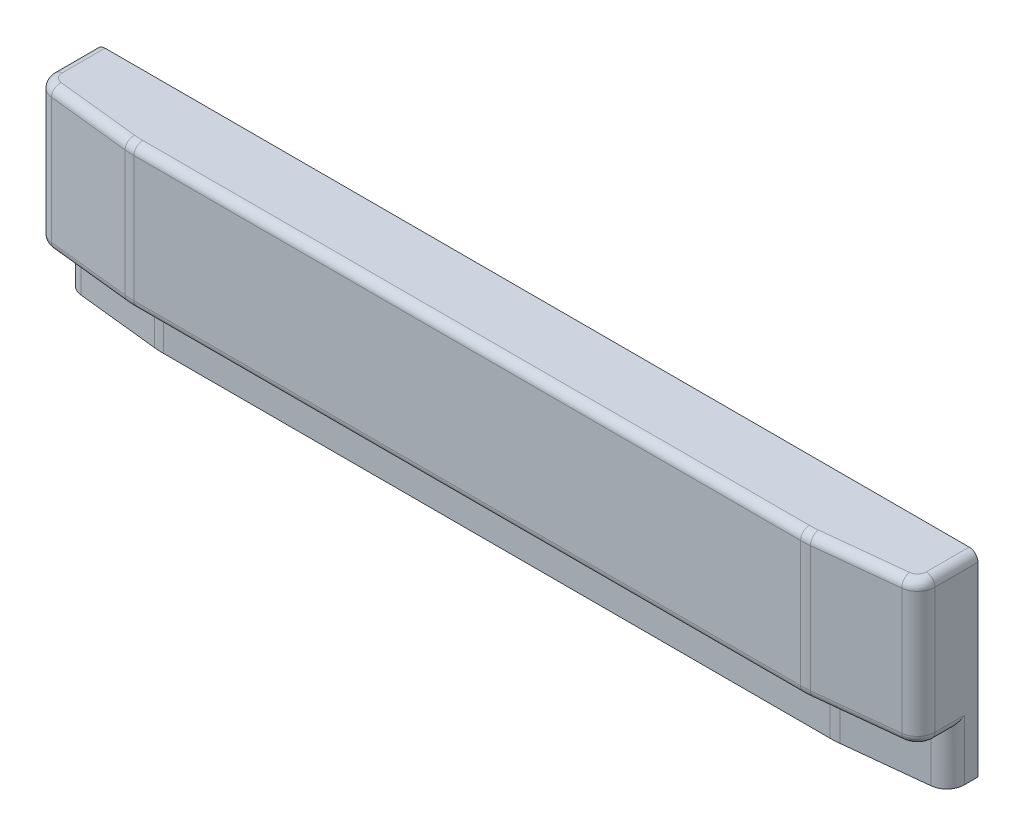
from build123d import *

# Parameters (mm, degrees)
BOSS_EXTRUDE1_DEPTH = 168.275
CUT_EXTRUDE1_DEPTH  = 44.45
FILLET1_R           = 15.24
FILLET2_R           = 76.2
FILLET3_R           = 7.62
FILLET4_R           = 7.62


with BuildPart() as part:
    # Sketch7 → Boss-Extrude1 (new body)
    with BuildSketch(Plane(origin=(0, 0, 0), x_dir=(1, 0, 0), z_dir=(0, 1, 0))):
        Polygon((0, 0), (762, 0), (762, -50.8), (673.1, -60.325), (88.9, -60.325), (0, -50.8), align=None)
    extrude(amount=BOSS_EXTRUDE1_DEPTH)

    # Sketch10 → Cut-Extrude1 (cut)
    with BuildSketch(Plane.XZ):
        Polygon((0, 50.8), (0, 25.4), (88.9, 34.925), (673.1, 34.925), (762, 25.4), (762, 50.8), (673.1, 60.325), (88.9, 60.325), align=None)
    extrude(amount=-CUT_EXTRUDE1_DEPTH, mode=Mode.SUBTRACT)

    # Fillet1
    fillet1_edges = [part.edges().sort_by_distance(p)[0] for p in [
        (762, 106.3625, 50.8),
        (0, 106.3625, 50.8),
        (762, 22.225, 25.4),
        (0, 22.225, 25.4),
    ]]
    fillet(fillet1_edges, radius=FILLET1_R)

    # Fillet2
    fillet2_edges = [part.edges().sort_by_distance(p)[0] for p in [
        (673.1, 106.3625, 60.325),
        (88.9, 106.3625, 60.325),
        (673.1, 22.225, 34.925),
        (88.9, 22.225, 34.925),
    ]]
    fillet(fillet2_edges, radius=FILLET2_R)

    # Fillet3
    fillet3_edges = [part.edges().sort_by_distance(p)[0] for p in [
        (762, 168.275, 18.552816133),
        (0, 168.275, 18.552816133),
        (49.234552732, 168.275, 56.07513065),
        (3.904199904, 168.275, 47.291761863),
        (758.095800096, 168.275, 47.291761863),
        (712.765447268, 168.275, 56.07513065),
        (381, 168.275, 60.325),
        (88.905795265, 168.275, 60.216512154),
        (673.094204735, 168.275, 60.216512154),
    ]]
    fillet(fillet3_edges, radius=FILLET3_R)

    # Fillet4
    fillet4_edges = [part.edges().sort_by_distance(p)[0] for p in [
        (762, 44.45, 18.552816133),
        (0, 44.45, 18.552816133),
        (712.765447268, 44.45, 56.07513065),
        (3.904199904, 44.45, 47.291761863),
        (758.095800096, 44.45, 47.291761863),
        (381, 44.45, 60.325),
        (49.234552732, 44.45, 56.07513065),
        (88.905795265, 44.45, 60.216512154),
        (673.094204735, 44.45, 60.216512154),
    ]]
    fillet(fillet4_edges, radius=FILLET4_R)


solid = part.part
